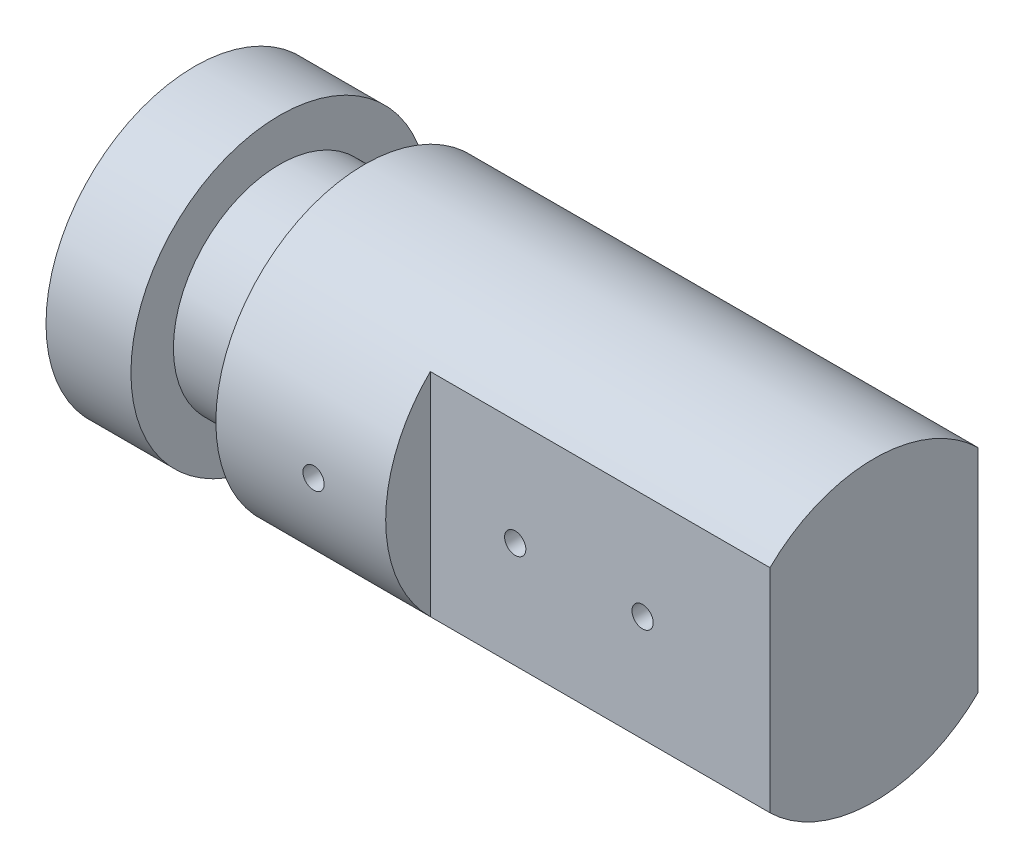
from build123d import *

# Parameters (mm, degrees)
M3X0_5_TAPPED_HOLE1_D               = 2.5
M3X0_5_TAPPED_HOLE1_DEPTH           = 3.248924226
M3X0_5_TAPPED_HOLE1_TIP             = 0.751075774
BOSS_EXTRUDE1_DEPTH                 = 40
M3X0_5_TAPPED_HOLE2_D               = 2.5
M3X0_5_TAPPED_HOLE2_DEPTH           = 5
M3X0_5_TAPPED_HOLE2_TIP             = 0.751075774
M3X0_5_TAPPED_HOLE2_ON_FACE_2_D     = 2.5
M3X0_5_TAPPED_HOLE2_ON_FACE_2_DEPTH = 5
M3X0_5_TAPPED_HOLE2_ON_FACE_2_TIP   = 0.751075774


with BuildPart() as part:
    # Sketch1 → Revolve1 (revolve)
    with BuildSketch(Plane.XY):
        Polygon((0, 0), (0, 17.5), (10, 17.5), (10, 12.5), (20, 12.5), (20, 17.5), (40, 17.5), (40, 0), align=None)
    revolve(axis=Axis((0, 0, 0), (1, 0, 0)))

    # M3x0.5 Tapped Hole1
    with Locations(Plane(origin=(31.5, 0, 17.5), x_dir=(1, 0, 0), z_dir=(0, 0, 1))):
        with Locations((0, 0)):
            Hole(M3X0_5_TAPPED_HOLE1_D / 2, depth=M3X0_5_TAPPED_HOLE1_DEPTH)
            with Locations((0, 0, -(M3X0_5_TAPPED_HOLE1_DEPTH + M3X0_5_TAPPED_HOLE1_TIP / 2))):  # 118° drill point
                Cone(0, M3X0_5_TAPPED_HOLE1_D / 2, M3X0_5_TAPPED_HOLE1_TIP, mode=Mode.SUBTRACT)

    # Sketch3 → Boss-Extrude1 (add)
    with BuildSketch(Plane(origin=(40, 0, 0), x_dir=(0, 0, -1), z_dir=(1, 0, 0))):
        with BuildLine():
            Line((-12.247448714, -12.5), (-12.247448714, 12.5))
            ThreePointArc((-12.247448714, 12.5), (0, 17.5), (12.247448714, 12.5))
            Line((12.247448714, 12.5), (12.247448714, -12.5))
            ThreePointArc((12.247448714, -12.5), (0, -17.5), (-12.247448714, -12.5))
        make_face()
    extrude(amount=BOSS_EXTRUDE1_DEPTH)

    # M3x0.5 Tapped Hole2
    with Locations(Plane(origin=(50, 0, 12.247448714), x_dir=(1, 0, 0), z_dir=(0, 0, 1))):
        with Locations((0, 0), (15, 0)):
            Hole(M3X0_5_TAPPED_HOLE2_D / 2, depth=M3X0_5_TAPPED_HOLE2_DEPTH)
            with Locations((0, 0, -(M3X0_5_TAPPED_HOLE2_DEPTH + M3X0_5_TAPPED_HOLE2_TIP / 2))):  # 118° drill point
                Cone(0, M3X0_5_TAPPED_HOLE2_D / 2, M3X0_5_TAPPED_HOLE2_TIP, mode=Mode.SUBTRACT)

    # M3x0.5 Tapped Hole2 on face 2
    with Locations(Plane(origin=(65, 0, -12.247448714), x_dir=(-1, 0, 0), z_dir=(0, 0, -1))):
        with Locations((0, 0), (15, 0)):
            Hole(M3X0_5_TAPPED_HOLE2_ON_FACE_2_D / 2, depth=M3X0_5_TAPPED_HOLE2_ON_FACE_2_DEPTH)
            with Locations((0, 0, -(M3X0_5_TAPPED_HOLE2_ON_FACE_2_DEPTH + M3X0_5_TAPPED_HOLE2_ON_FACE_2_TIP / 2))):  # 118° drill point
                Cone(0, M3X0_5_TAPPED_HOLE2_ON_FACE_2_D / 2, M3X0_5_TAPPED_HOLE2_ON_FACE_2_TIP, mode=Mode.SUBTRACT)


solid = part.part
